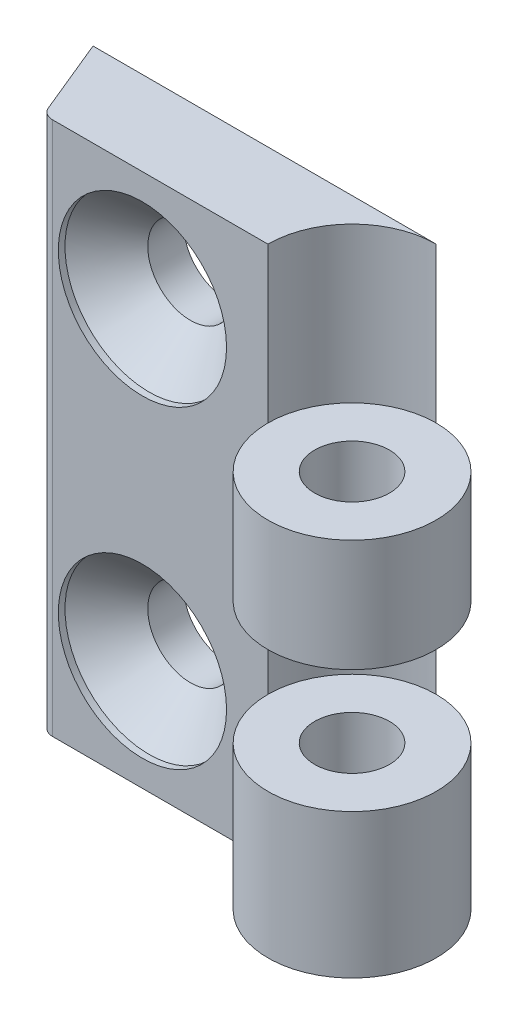
from build123d import *

# Parameters (mm, degrees)
SKETCH1_R                                    = 2.8
BOSS_EXTRUDE1_DEPTH                          = 10.8
BOSS_EXTRUDE2_DEPTH                          = 40
BOSS_EXTRUDE5_START                          = 20
SKETCH1_7_R                                  = 2.8
BOSS_EXTRUDE5_DEPTH                          = 8.4
CSK_FOR_M6_COUNTERSUNK_FLAT_HEAD_SCR_2_COUNT = 2
CSK_FOR_M6_COUNTERSUNK_FLAT_HEAD_SCR_2_PITCH = 23.5


with BuildPart() as part:
    # Sketch1 → Boss-Extrude1 (new body)
    with BuildSketch(Plane(origin=(0, 0, 0), x_dir=(1, 0, 0), z_dir=(0, 1, 0))):
        with BuildLine():
            Line((-22.433809621, 0), (-6.3, 0))
            ThreePointArc((-6.3, 0), (4.454772721, -4.454772721), (0, 6.3))
            Line((0, 6.3), (-25.7, 6.3))
            Line((-25.7, 6.3), (-23.358351291, 0.618919036))
            ThreePointArc((-23.358351291, 0.618919036), (-22.990100479, 0.169012346), (-22.433809621, 0))
        make_face()
        Circle(SKETCH1_R, mode=Mode.SUBTRACT)
    extrude(amount=BOSS_EXTRUDE1_DEPTH)

    # Sketch1_3 → Boss-Extrude2 (add)
    with BuildSketch(Plane(origin=(0, 0, 0), x_dir=(1, 0, 0), z_dir=(0, 1, 0))):
        with BuildLine():
            ThreePointArc((-6.3, 0), (-4.454772721, 4.454772721), (0, 6.3))
            Line((0, 6.3), (-25.7, 6.3))
            Line((-25.7, 6.3), (-23.358351291, 0.618919036))
            ThreePointArc((-23.358351291, 0.618919036), (-22.990100479, 0.169012346), (-22.433809621, 0))
            Line((-22.433809621, 0), (-6.3, 0))
        make_face()
    extrude(amount=BOSS_EXTRUDE2_DEPTH)

    # Sketch1_7 → Boss-Extrude5 (add)
    with BuildSketch(Plane(origin=(0, 0, 0), x_dir=(1, 0, 0), z_dir=(0, 1, 0)).offset(BOSS_EXTRUDE5_START)):
        with BuildLine():
            ThreePointArc((6.3, 0), (4.454772721, 4.454772721), (0, 6.3))
            ThreePointArc((0, 6.3), (-4.454772721, 4.454772721), (-6.3, 0))
            ThreePointArc((-6.3, 0), (0, -6.3), (6.3, 0))
        make_face()
        Circle(SKETCH1_7_R, mode=Mode.SUBTRACT)
    extrude(amount=BOSS_EXTRUDE5_DEPTH)

    # Sketch3 → CSK for M6 Countersunk Flat Head Screw1 (revolve, cut)
    with BuildSketch(Plane(origin=(-15.7, 31.75, 0), x_dir=(0, -1, 0), z_dir=(1, 0, 0))):
        Polygon((0, 0), (0, 6.3), (3.2, 6.3), (3.2, 3.6), (6.3, 0.5), (6.3, 0), align=None)
    csk_for_m6_countersunk_flat_head_screw1 = revolve(axis=Axis((-15.7, 31.75, 6.35), (0, 0, -1)), mode=Mode.SUBTRACT)

    # CSK for M6 Countersunk Flat Head Scr 2: CSK for M6 Countersunk Flat Head Screw1 ×2
    with Locations(*[(0, -i * CSK_FOR_M6_COUNTERSUNK_FLAT_HEAD_SCR_2_PITCH, 0) for i in range(1, CSK_FOR_M6_COUNTERSUNK_FLAT_HEAD_SCR_2_COUNT)]):
        add(csk_for_m6_countersunk_flat_head_screw1, mode=Mode.SUBTRACT)


solid = part.part
